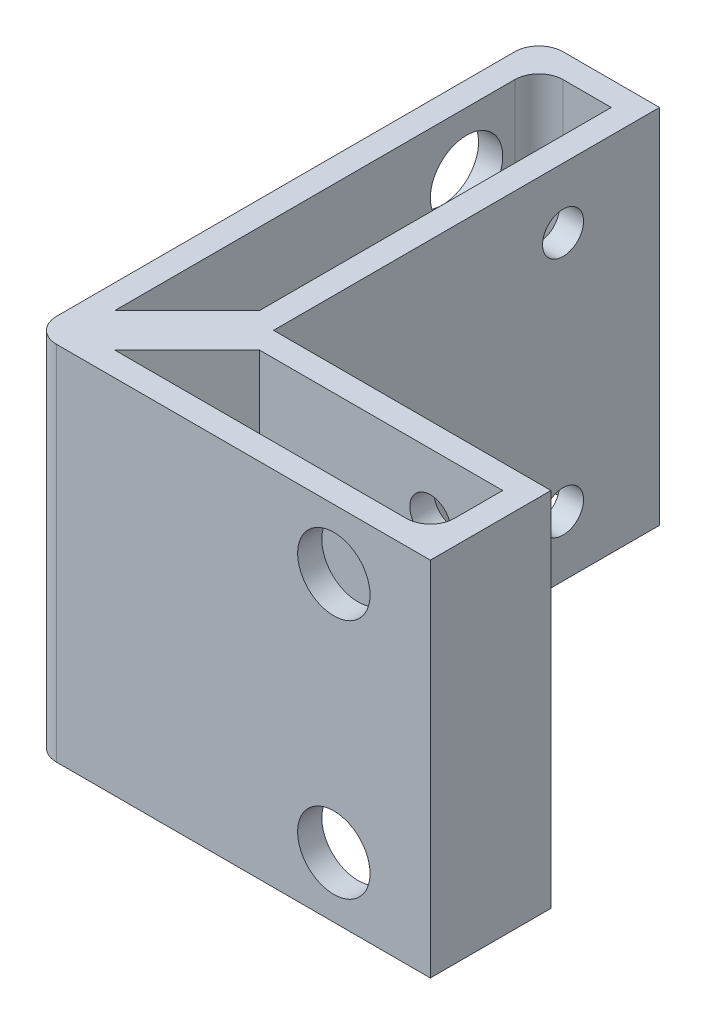
from build123d import *

# Parameters (mm, degrees)
BOSS_EXTRUDE1_DEPTH            = 15
FILLET1_R                      = 2
M3_CLEARANCE_HOLE1_D           = 3.4
M3_CLEARANCE_HOLE1_ON_FACE_2_D = 3.4
SKETCH3_R                      = 3
CUT_EXTRUDE1_DEPTH             = 8
SKETCH4_R                      = 3
CUT_EXTRUDE2_DEPTH             = 8


with BuildPart() as part:
    # Sketch1 → Boss-Extrude1 (new body, symmetric)
    with BuildSketch(Plane(origin=(0, 0, 0), x_dir=(1, 0, 0), z_dir=(0, 1, 0))):
        Polygon((0, 0), (0, 32), (-10, 32), (-10, -10), (23, -10), (23, 0), align=None)
        Polygon((-8, 30), (-2, 30), (-2, 0.828427125), (-8, -5.171572875), align=None, mode=Mode.SUBTRACT)
        Polygon((21, -8), (-5.171572875, -8), (0.828427125, -2), (21, -2), align=None, mode=Mode.SUBTRACT)
    extrude(amount=BOSS_EXTRUDE1_DEPTH, both=True)

    # Fillet1
    fillet1_edges = [part.edges().sort_by_distance(p)[0] for p in [
        (-10, 0, 10),
        (-10, 0, -32),
        (21, 0, 8),
        (-8, 0, -30),
    ]]
    fillet(fillet1_edges, radius=FILLET1_R)

    # M3 Clearance Hole1 (through all)
    with Locations(Plane(origin=(15, -10, 0), x_dir=(-1, 0, 0), z_dir=(0, 0, -1))):
        with Locations((0, 0), (0, 20)):
            Hole(M3_CLEARANCE_HOLE1_D / 2)

    # M3 Clearance Hole1 on face 2 (through all)
    with Locations(Plane(origin=(0, 10, -24), x_dir=(0, 0, 1), z_dir=(1, 0, 0))):
        with Locations((0, 0), (0, 20)):
            Hole(M3_CLEARANCE_HOLE1_ON_FACE_2_D / 2)

    # Sketch3 → Cut-Extrude1 (cut)
    with BuildSketch(Plane.ZY.offset(10)):
        with Locations((-24, 10)):
            Circle(SKETCH3_R)
        with Locations((-24, -10)):
            Circle(SKETCH3_R)
    extrude(amount=-CUT_EXTRUDE1_DEPTH, mode=Mode.SUBTRACT)

    # Sketch4 → Cut-Extrude2 (cut)
    with BuildSketch(Plane.XY.offset(10)):
        with Locations((15, 10)):
            Circle(SKETCH4_R)
        with Locations((15, -10)):
            Circle(SKETCH4_R)
    extrude(amount=-CUT_EXTRUDE2_DEPTH, mode=Mode.SUBTRACT)


solid = part.part
